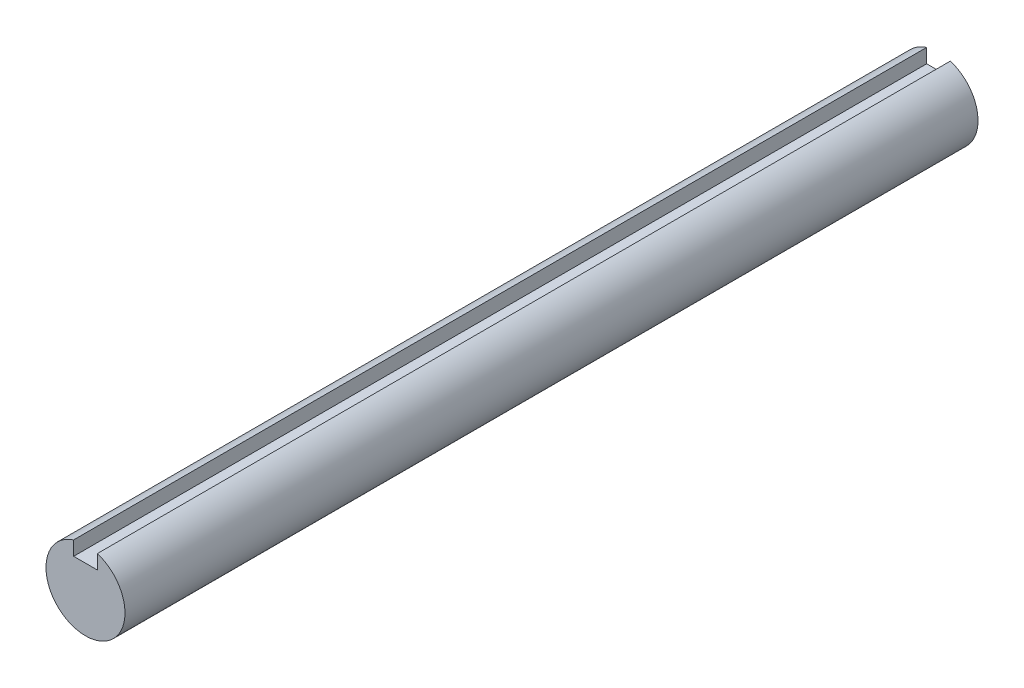
from build123d import *

# Parameters (mm, degrees)
BOSS_EXTRUDE1_DEPTH      = 53.975
BOSS_EXTRUDE1_DEPTH_BACK = 53.975


with BuildPart() as part:
    # Sketch3 → Boss-Extrude1 (new body, two sides)
    with BuildSketch(Plane.XY) as boss_extrude1_sk:
        with BuildLine():
            Line((-1.5, 2.969696007), (-1.5, 4.769696007))
            ThreePointArc((-1.5, 4.769696007), (0, -5), (1.5, 4.769696007))
            Line((1.5, 4.769696007), (1.5, 2.969696007))
            Line((1.5, 2.969696007), (-1.5, 2.969696007))
        make_face()
    extrude(amount=BOSS_EXTRUDE1_DEPTH)
    extrude(boss_extrude1_sk.sketch, amount=-BOSS_EXTRUDE1_DEPTH_BACK)


solid = part.part
